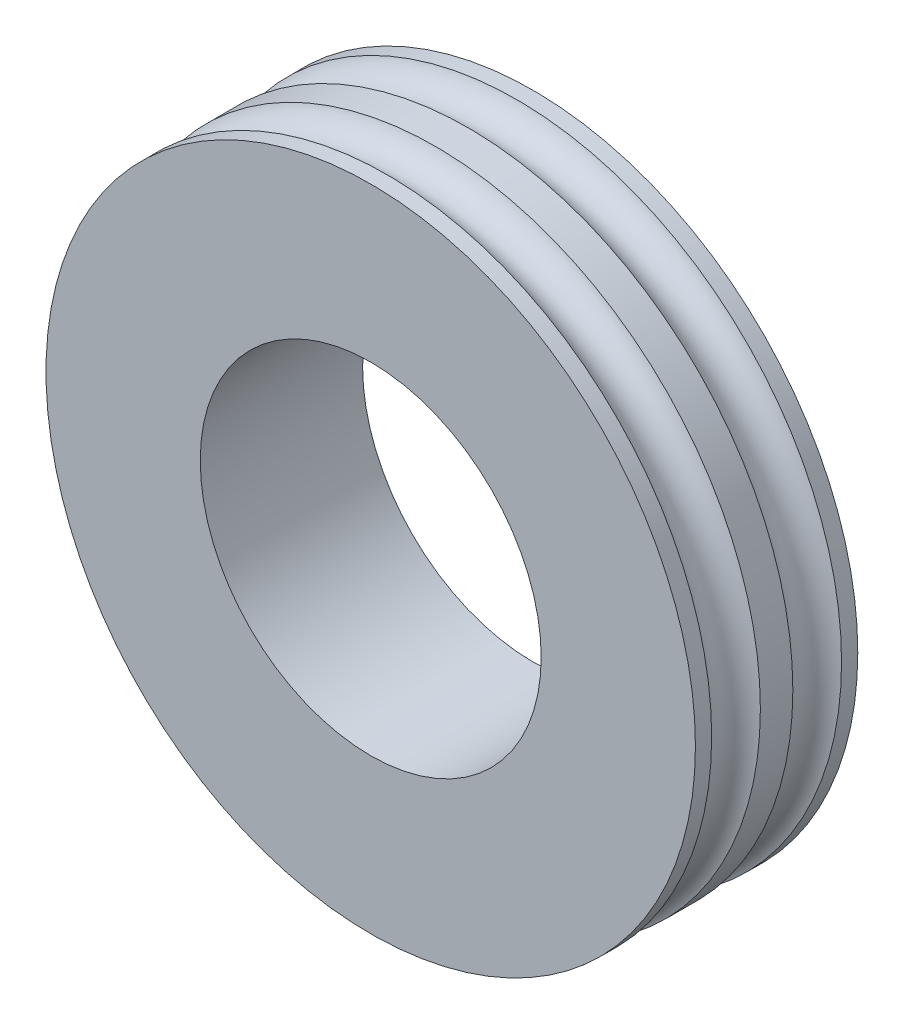
from build123d import *


with BuildPart() as part:
    # Sketch2 → Revolve1 (revolve)
    with BuildSketch(Plane(origin=(0, 0, 0), x_dir=(0, 0, -1), z_dir=(1, 0, 0))):
        with BuildLine():
            Line((0, 2.1), (0, 4))
            Line((0, 4), (-0.2, 4))
            ThreePointArc((-0.2, 4), (-0.5, 3.783772234), (-0.8, 4))
            Line((-0.8, 4), (-1, 4))
            Line((-1, 4), (-1, 2.1))
            Line((-1, 2.1), (0, 2.1))
        make_face()
    revolve1 = revolve(axis=Axis((0, 0, 3.014677367), (0, 0, -1)))

    # Mirror2: Revolve1 across plane
    add(revolve1.mirror(Plane(origin=(0, 0, 0), x_dir=(1, 0, 0), z_dir=(0, 0, -1))))


solid = part.part
